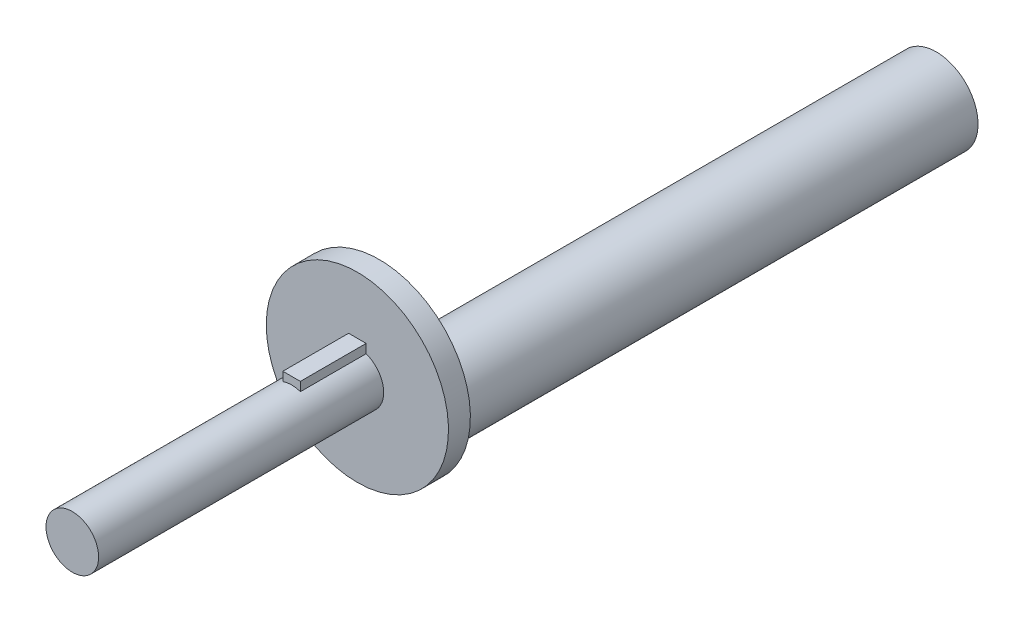
from build123d import *

# Parameters (mm, degrees)
BOSS_EXTRUDE1_DEPTH = 15
SKETCH2_R           = 20.775
BOSS_EXTRUDE2_DEPTH = 5
SKETCH3_R           = 9.525
BOSS_EXTRUDE3_DEPTH = 127
SKETCH6_R           = 6
BOSS_EXTRUDE5_DEPTH = 50


with BuildPart() as part:
    # Sketch1 → Boss-Extrude1 (new body)
    with BuildSketch(Plane.XY):
        with BuildLine():
            Line((-2, 7.7), (2, 7.7))
            Line((2, 7.7), (2, 5.656854249))
            ThreePointArc((2, 5.656854249), (0, -6), (-2, 5.656854249))
            Line((-2, 5.656854249), (-2, 7.7))
        make_face()
    extrude(amount=BOSS_EXTRUDE1_DEPTH)

    # Sketch2 → Boss-Extrude2 (add)
    with BuildSketch(Plane(origin=(0, 0, 0), x_dir=(-1, 0, 0), z_dir=(0, 0, -1))):
        Circle(SKETCH2_R)
    extrude(amount=BOSS_EXTRUDE2_DEPTH)

    # Sketch3 → Boss-Extrude3 (add)
    with BuildSketch(Plane(origin=(0, 0, -5), x_dir=(-1, 0, 0), z_dir=(0, 0, -1))):
        with Locations((0, -11.25)):
            Circle(SKETCH3_R)
    extrude(amount=BOSS_EXTRUDE3_DEPTH)

    # Sketch6 → Boss-Extrude5 (add)
    with BuildSketch(Plane.XY.offset(15)):
        Circle(SKETCH6_R)
    extrude(amount=BOSS_EXTRUDE5_DEPTH)


solid = part.part
